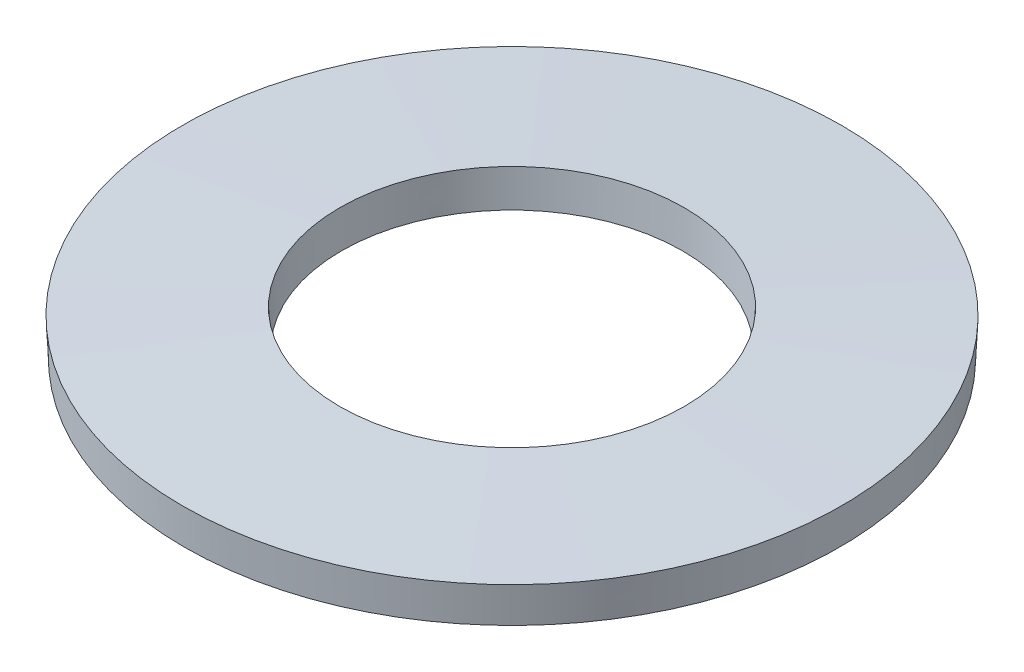
from build123d import *


with BuildPart() as part:
    # Skizze1 → Rotation1 (revolve)
    with BuildSketch(Plane(origin=(0, 0, 0), x_dir=(0, 0, -1), z_dir=(1, 0, 0))):
        Polygon((-15.668174828, 0), (-8.15, 0.351914006), (-8.231825172, 2.1), (-15.75, 1.748085994), align=None)
    revolve(axis=Axis((0, 0, 0), (0, 1, 0)))


solid = part.part
